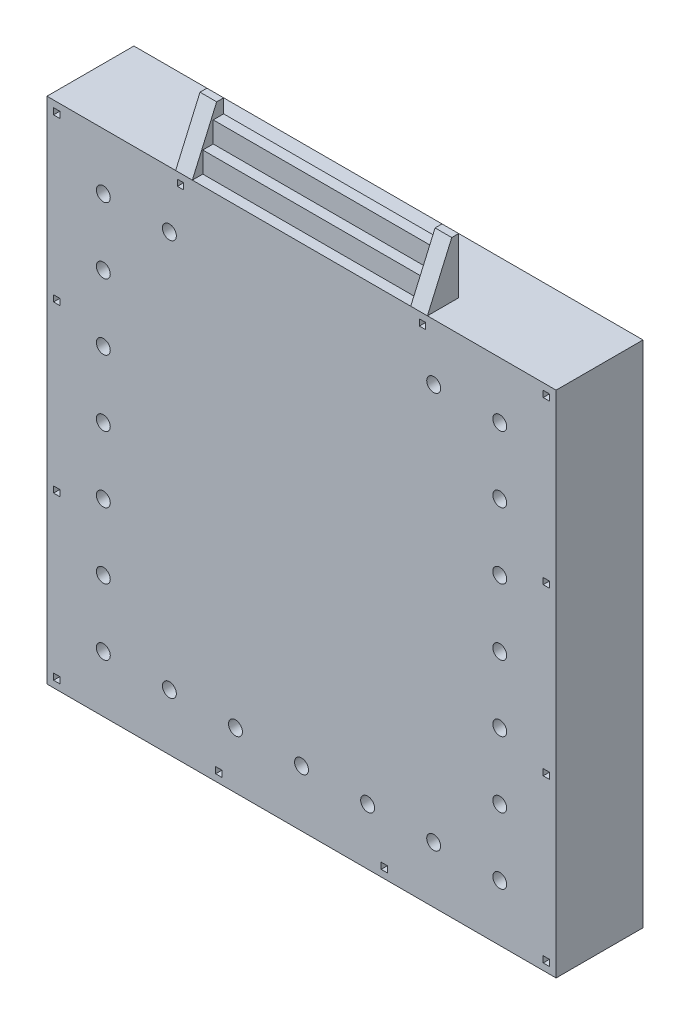
from build123d import *

# Parameters (mm, degrees)
SKETCH_1_W          = 7320
SKETCH_1_H          = 7320
EXTRUDE_1_DEPTH     = 1250
SKETCH_2_R          = 100
CUT_EXTRUDE_2_DEPTH = 150
SKETCH_9_W          = 90
SKETCH_9_H          = 90
CUT_EXTRUDE_3_DEPTH = 150
SKETCH_10_R         = 100
CUT_EXTRUDE_4_DEPTH = 150
EXTRUDE_2_DEPTH     = 3620
CUT_EXTRUDE_5_DEPTH = 3140


with BuildPart() as part:
    # 草图1 → 凸台-拉伸1 (new body)
    with BuildSketch(Plane.XY):
        with Locations((1314.768469162, 2698.045948238)):
            Rectangle(SKETCH_1_W, SKETCH_1_H)
    extrude(amount=-EXTRUDE_1_DEPTH)

    # 草图2 → 切除-拉伸2 (cut)
    with BuildSketch(Plane.XY):
        with Locations((-1535.231530838, 5548.045948238)):
            Circle(SKETCH_2_R)
        with Locations((4164.768469162, 5548.045948238)):
            Circle(SKETCH_2_R)
        with Locations((-1535.231530838, -151.954051762)):
            Circle(SKETCH_2_R)
        with Locations((4164.768469162, -151.954051762)):
            Circle(SKETCH_2_R)
    extrude(amount=-CUT_EXTRUDE_2_DEPTH, mode=Mode.SUBTRACT)

    # 草图9 → 切除-拉伸3 (cut)
    with BuildSketch(Plane.XY):
        with Locations((-2205.231530838, 6218.045948238)):
            Rectangle(SKETCH_9_W, SKETCH_9_H)
        with Locations((-2205.231530838, 3888.045948238)):
            Rectangle(SKETCH_9_W, SKETCH_9_H)
        with Locations((-2205.231530838, 1508.045948238)):
            Rectangle(SKETCH_9_W, SKETCH_9_H)
        with Locations((-2205.231530838, -821.954051762)):
            Rectangle(SKETCH_9_W, SKETCH_9_H)
        with Locations((124.768469162, -821.954051762)):
            Rectangle(SKETCH_9_W, SKETCH_9_H)
        with Locations((2504.768469162, -821.954051762)):
            Rectangle(SKETCH_9_W, SKETCH_9_H)
        with Locations((4834.768469162, -821.954051762)):
            Rectangle(SKETCH_9_W, SKETCH_9_H)
        with Locations((4834.768469162, 1508.045948238)):
            Rectangle(SKETCH_9_W, SKETCH_9_H)
        with Locations((4834.768469162, 3888.045948238)):
            Rectangle(SKETCH_9_W, SKETCH_9_H)
        with Locations((4834.768469162, 6218.045948238)):
            Rectangle(SKETCH_9_W, SKETCH_9_H)
        with Locations((3054.768469162, 6218.045948238)):
            Rectangle(SKETCH_9_W, SKETCH_9_H)
        with Locations((-425.231530838, 6218.045948238)):
            Rectangle(SKETCH_9_W, SKETCH_9_H)
    extrude(amount=-CUT_EXTRUDE_3_DEPTH, mode=Mode.SUBTRACT)

    # 草图10 → 切除-拉伸4 (cut)
    with BuildSketch(Plane.XY):
        with Locations((-585.231530838, 5548.045948238)):
            Circle(SKETCH_10_R)
        with Locations((-1535.231530838, 3648.045948238)):
            Circle(SKETCH_10_R)
        with Locations((-1535.231530838, 1748.045948238)):
            Circle(SKETCH_10_R)
        with Locations((4164.768469162, 3648.045948238)):
            Circle(SKETCH_10_R)
        with Locations((4164.768469162, 1748.045948238)):
            Circle(SKETCH_10_R)
        with Locations((3214.768469162, 5548.045948238)):
            Circle(SKETCH_10_R)
        with Locations((-1535.231530838, 4598.045948238)):
            Circle(SKETCH_10_R)
        with Locations((-1535.231530838, 2698.045948238)):
            Circle(SKETCH_10_R)
        with Locations((-1535.231530838, 798.045948238)):
            Circle(SKETCH_10_R)
        with Locations((4164.768469162, 4598.045948238)):
            Circle(SKETCH_10_R)
        with Locations((4164.768469162, 2698.045948238)):
            Circle(SKETCH_10_R)
        with Locations((4164.768469162, 798.045948238)):
            Circle(SKETCH_10_R)
        with Locations((-585.231530838, -151.954051762)):
            Circle(SKETCH_10_R)
        with Locations((364.768469162, -151.954051762)):
            Circle(SKETCH_10_R)
        with Locations((1314.768469162, -151.954051762)):
            Circle(SKETCH_10_R)
        with Locations((2264.768469162, -151.954051762)):
            Circle(SKETCH_10_R)
        with Locations((3214.768469162, -151.954051762)):
            Circle(SKETCH_10_R)
    extrude(amount=-CUT_EXTRUDE_4_DEPTH, mode=Mode.SUBTRACT)

    # 草图11 → 凸台-拉伸2 (add)
    with BuildSketch(Plane(origin=(3124.768469162, 0, 0), x_dir=(0, 0, -1), z_dir=(1, 0, 0))):
        Polygon((450, 7158.045948238), (450, 6358.045948238), (0, 6358.045948238), (350, 7158.045948238), align=None)
    extrude(amount=-EXTRUDE_2_DEPTH)

    # 草图14 → 切除-拉伸5 (cut)
    with BuildSketch(Plane.ZY.offset(-2884.768469162)):
        Polygon((-150, 6358.045948238), (-150, 6658.045948238), (-300, 6658.045948238), (-300, 6958.045948238), (-450, 6958.045948238), (-450, 7158.045948238), (-350, 7158.045948238), (0, 6358.045948238), align=None)
    extrude(amount=CUT_EXTRUDE_5_DEPTH, mode=Mode.SUBTRACT)


solid = part.part
